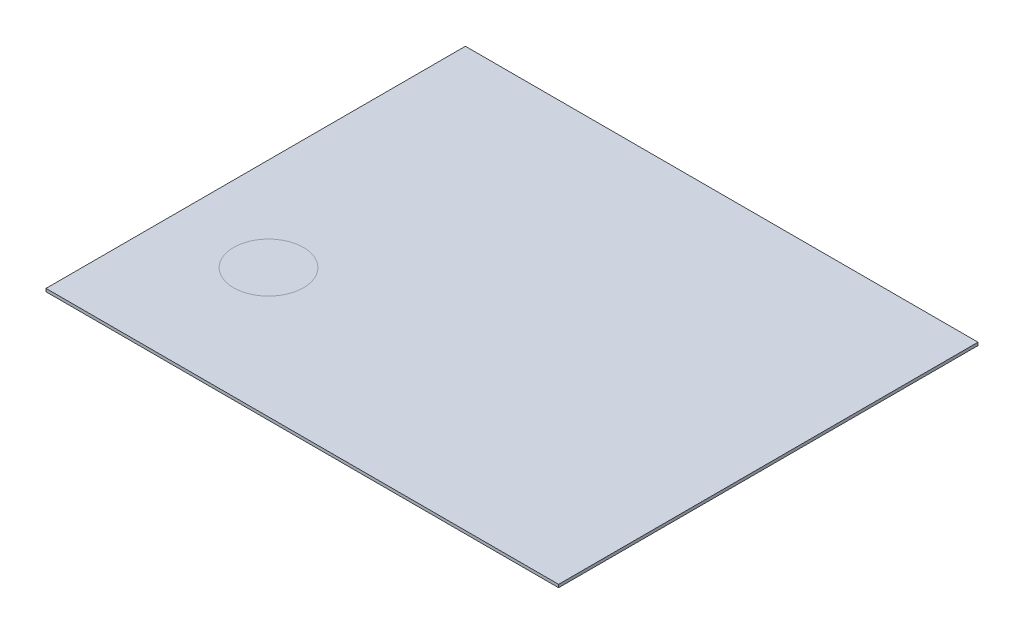
from build123d import *

# Parameters (mm, degrees)
SKETCH1_W           = 1100
SKETCH1_H           = 900
BOSS_EXTRUDE1_DEPTH = 6.35


with BuildPart() as part:
    # Sketch1 → Boss-Extrude1 (new body)
    with BuildSketch(Plane(origin=(0, 0, 0), x_dir=(1, 0, 0), z_dir=(0, 1, 0))):
        Rectangle(SKETCH1_W, SKETCH1_H)
    extrude(amount=BOSS_EXTRUDE1_DEPTH)


solid = part.part
